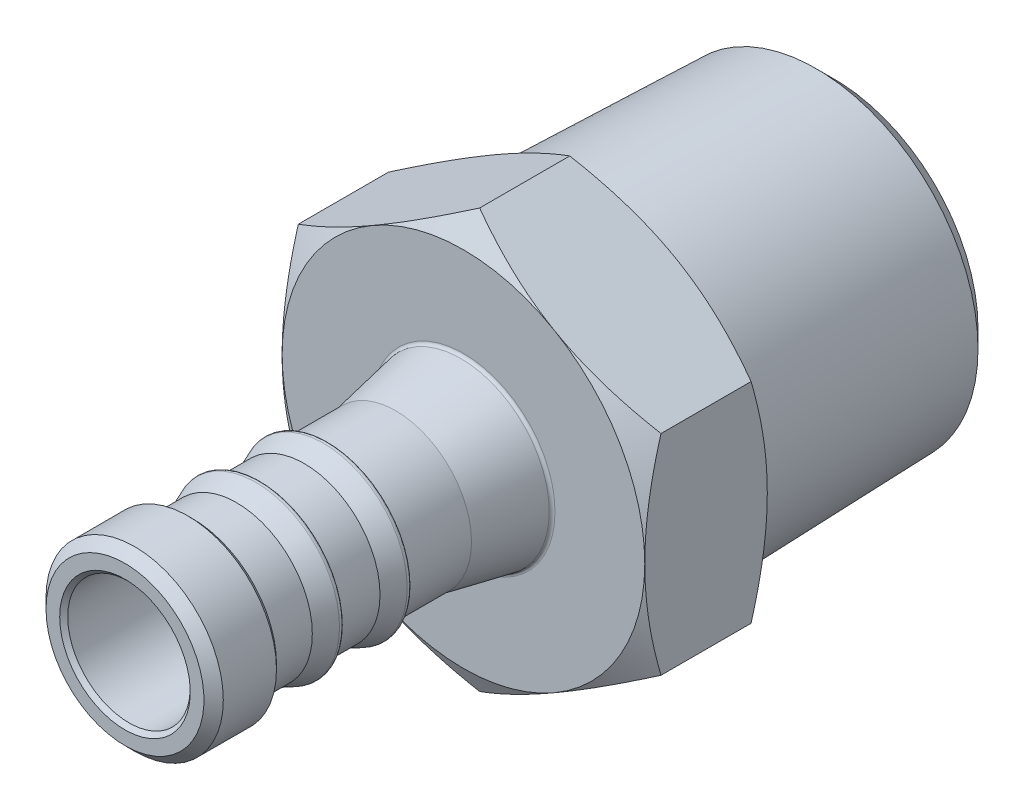
from build123d import *

# Parameters (mm, degrees)
CHAMFER1_SIZE       = 0.381
CHAMFER2_SIZE       = 0.762
SKETCH3_R           = 12.707475311
BOSS_EXTRUDE1_DEPTH = 19.558
BOSS_EXTRUDE1_TAPER = -1.78333333
SKETCH6_OUTSIDE_W   = 81.226
SKETCH6_OUTSIDE_H   = 81.226
SKETCH6_OUTSIDE_R   = 11.332659983
CUT_EXTRUDE1_DEPTH  = 19.558
CUT_EXTRUDE1_TAPER  = 45
BOSS_EXTRUDE2_DEPTH = 9.652
SKETCH8_OUTSIDE_W   = 78.192
SKETCH8_OUTSIDE_H   = 82.612
SKETCH8_OUTSIDE_R   = 14.2875
CUT_EXTRUDE2_DEPTH  = 9.652
CUT_EXTRUDE2_TAPER  = 60
SKETCH9_OUTSIDE_W   = 78.192
SKETCH9_OUTSIDE_H   = 82.612
SKETCH9_OUTSIDE_R   = 14.2875
CUT_EXTRUDE3_DEPTH  = 9.652
CUT_EXTRUDE3_TAPER  = 60
SKETCH10_W          = 36.322
SKETCH10_H          = 4.826
CHAMFER3_SIZE       = 0.3175
CHAMFER4_SIZE       = 0.508


with BuildPart() as part:
    # Sketch2 → Revolve1 (revolve)
    with BuildSketch(Plane(origin=(0, 0, 0), x_dir=(0, 0, -1), z_dir=(1, 0, 0))):
        with BuildLine():
            Line((-21.082, 5.969), (-17.87705275, 5.969))
            Line((-17.87705275, 5.969), (-16.351150075, 6.585504699))
            ThreePointArc((-16.351150075, 6.585504699), (-16.113965003, 6.560575543), (-16.002, 6.35))
            Line((-16.002, 6.35), (-16.002, 6.223))
            ThreePointArc((-16.002, 6.223), (-15.927605122, 6.043394878), (-15.748, 5.969))
            Line((-15.748, 5.969), (-12.54305275, 5.969))
            Line((-12.54305275, 5.969), (-11.017150075, 6.585504699))
            ThreePointArc((-11.017150075, 6.585504699), (-10.779965003, 6.560575543), (-10.668, 6.35))
            Line((-10.668, 6.35), (-10.668, 6.223))
            ThreePointArc((-10.668, 6.223), (-10.593605122, 6.043394878), (-10.414, 5.969))
            Line((-10.414, 5.969), (-5.334, 5.969))
            Line((-5.334, 5.969), (-0.205534515, 6.965872706))
            ThreePointArc((-0.205534515, 6.965872706), (-0.058007356, 7.053642143), (0, 7.215206011))
            Line((0, 7.215206011), (0, 0))
            Line((0, 0), (-26.67, 0))
            Line((-26.67, 0), (-26.67, 6.985))
            Line((-26.67, 6.985), (-21.336, 6.985))
            Line((-21.336, 6.985), (-21.336, 6.223))
            ThreePointArc((-21.336, 6.223), (-21.261605122, 6.043394878), (-21.082, 5.969))
        make_face()
    revolve(axis=Axis((0, 0, 26.67), (0, 0, -1)))

    # Chamfer1
    chamfer1_edges = [part.edges().sort_by_distance(p)[0] for p in [
        (0, -6.985, 21.336),
    ]]
    chamfer(chamfer1_edges, length=CHAMFER1_SIZE)

    # Chamfer2
    chamfer2_edges = [part.edges().sort_by_distance(p)[0] for p in [
        (0, -6.985, 26.67),
    ]]
    chamfer(chamfer2_edges, length=CHAMFER2_SIZE)



with BuildPart() as body_2:
    # Sketch3 → Boss-Extrude1 (new body)
    with BuildSketch(Plane.XY.offset(-29.21)):
        Circle(SKETCH3_R)
    extrude(amount=BOSS_EXTRUDE1_DEPTH, taper=BOSS_EXTRUDE1_TAPER)

    # Sketch6 outside → Cut-Extrude1 (cut)
    with BuildSketch(Plane(origin=(0, 0, -29.21), x_dir=(-1, 0, 0), z_dir=(0, 0, -1))):
        Rectangle(SKETCH6_OUTSIDE_W, SKETCH6_OUTSIDE_H)
        Circle(SKETCH6_OUTSIDE_R, mode=Mode.SUBTRACT)
    extrude(amount=-CUT_EXTRUDE1_DEPTH, taper=CUT_EXTRUDE1_TAPER, mode=Mode.SUBTRACT)


with BuildPart() as part_1:
    add(part.part)

    add(body_2.part)  # Boss-Extrude2 merges body 2
    # Sketch7 → Boss-Extrude2 (add)
    with BuildSketch(Plane(origin=(0, 0, 0), x_dir=(-1, 0, 0), z_dir=(0, 0, -1))):
        Polygon((0, 16.497783942), (-14.2875, 8.248891971), (-14.2875, -8.248891971), (0, -16.497783942), (14.2875, -8.248891971), (14.2875, 8.248891971), align=None)
    extrude(amount=BOSS_EXTRUDE2_DEPTH)

    # Sketch8 outside → Cut-Extrude2 (cut)
    with BuildSketch(Plane.XY):
        Rectangle(SKETCH8_OUTSIDE_W, SKETCH8_OUTSIDE_H)
        Circle(SKETCH8_OUTSIDE_R, mode=Mode.SUBTRACT)
    extrude(amount=-CUT_EXTRUDE2_DEPTH, taper=CUT_EXTRUDE2_TAPER, mode=Mode.SUBTRACT)

    # Sketch9 outside → Cut-Extrude3 (cut)
    with BuildSketch(Plane(origin=(0, 0, -9.652), x_dir=(-1, 0, 0), z_dir=(0, 0, -1))):
        Rectangle(SKETCH9_OUTSIDE_W, SKETCH9_OUTSIDE_H)
        Circle(SKETCH9_OUTSIDE_R, mode=Mode.SUBTRACT)
    extrude(amount=-CUT_EXTRUDE3_DEPTH, taper=CUT_EXTRUDE3_TAPER, mode=Mode.SUBTRACT)

    # Sketch10 → Cut-Revolve1 (revolve, cut)
    with BuildSketch(Plane(origin=(0, 0, 0), x_dir=(0, 0, -1), z_dir=(1, 0, 0))):
        with Locations((-8.509, 2.413)):
            Rectangle(SKETCH10_W, SKETCH10_H)
    revolve(axis=Axis((0, 0, 0), (0, 0, 1)), mode=Mode.SUBTRACT)

    # Chamfer3
    chamfer3_edges = [part_1.edges().sort_by_distance(p)[0] for p in [
        (0, -4.826, 26.67),
    ]]
    chamfer(chamfer3_edges, length=CHAMFER3_SIZE)

    # Sketch11 → Cut-Revolve2 (revolve, cut)
    with BuildSketch(Plane(origin=(0, 0, 0), x_dir=(0, 0, -1), z_dir=(1, 0, 0))):
        Polygon((29.21, 0), (29.21, 6.4135), (9.652, 6.4135), (5.79838042, 0), align=None)
    revolve(axis=Axis((0, 0, 0), (0, 0, -1)), mode=Mode.SUBTRACT)

    # Chamfer4
    chamfer4_edges = [part_1.edges().sort_by_distance(p)[0] for p in [
        (0, -6.4135, -29.21),
    ]]
    chamfer(chamfer4_edges, length=CHAMFER4_SIZE)


solid = part_1.part
